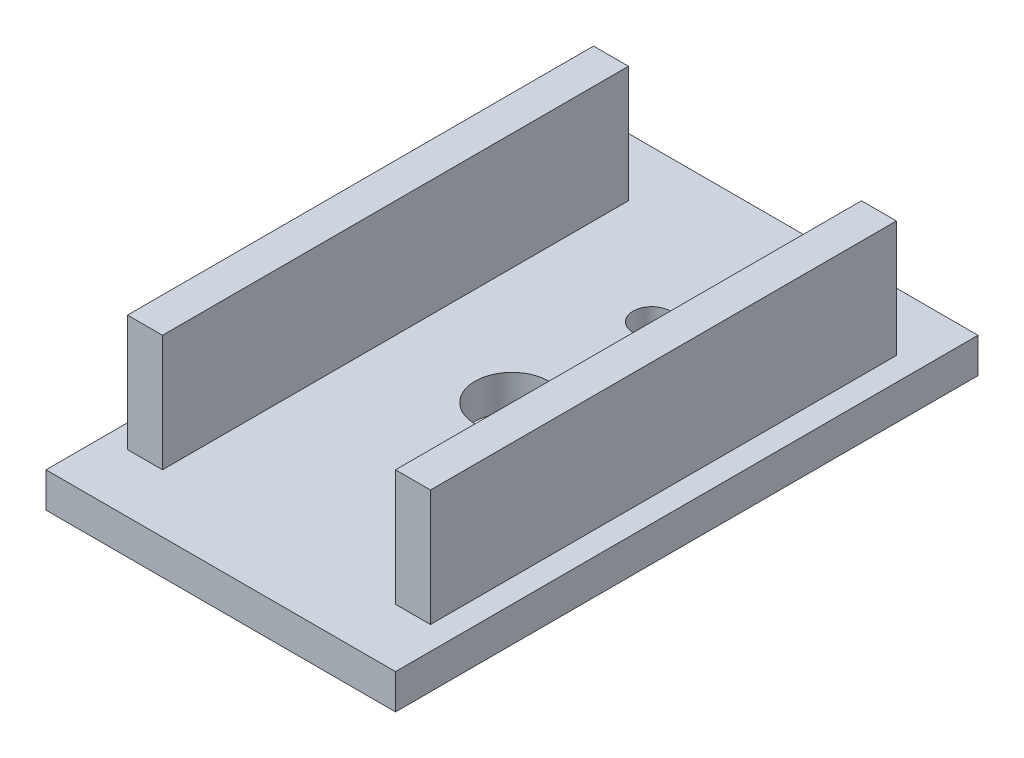
from build123d import *

# Parameters (mm, degrees)
SKETCH1_W           = 30
SKETCH1_H           = 50
BOSS_EXTRUDE1_DEPTH = 1.5
SKETCH2_R           = 3.175
SKETCH2_R_2         = 1.6
CUT_EXTRUDE1_DEPTH  = 3
SKETCH3_W           = 3
SKETCH3_H           = 40
BOSS_EXTRUDE2_DEPTH = 10


with BuildPart() as part:
    # Sketch1 → Boss-Extrude1 (new body, symmetric)
    with BuildSketch(Plane(origin=(0, 0, 0), x_dir=(1, 0, 0), z_dir=(0, 1, 0))):
        Rectangle(SKETCH1_W, SKETCH1_H)
    extrude(amount=BOSS_EXTRUDE1_DEPTH, both=True)

    # Sketch2 → Cut-Extrude1 (cut)
    with BuildSketch(Plane(origin=(0, 1.5, 0), x_dir=(1, 0, 0), z_dir=(0, 1, 0))):
        Circle(SKETCH2_R)
        with Locations((0, 12)):
            Circle(SKETCH2_R_2)
    extrude(amount=-CUT_EXTRUDE1_DEPTH, mode=Mode.SUBTRACT)

    # Sketch3 → Boss-Extrude2 (add)
    with BuildSketch(Plane(origin=(0, 1.5, 0), x_dir=(1, 0, 0), z_dir=(0, 1, 0))):
        with Locations((11.5, 0)):
            Rectangle(SKETCH3_W, SKETCH3_H)
    boss_extrude2 = extrude(amount=BOSS_EXTRUDE2_DEPTH)

    # Mirror1: Boss-Extrude2 across plane
    add(boss_extrude2.mirror(Plane(origin=(0, 0, 0), x_dir=(0, 0, 1), z_dir=(1, 0, 0))))


solid = part.part
